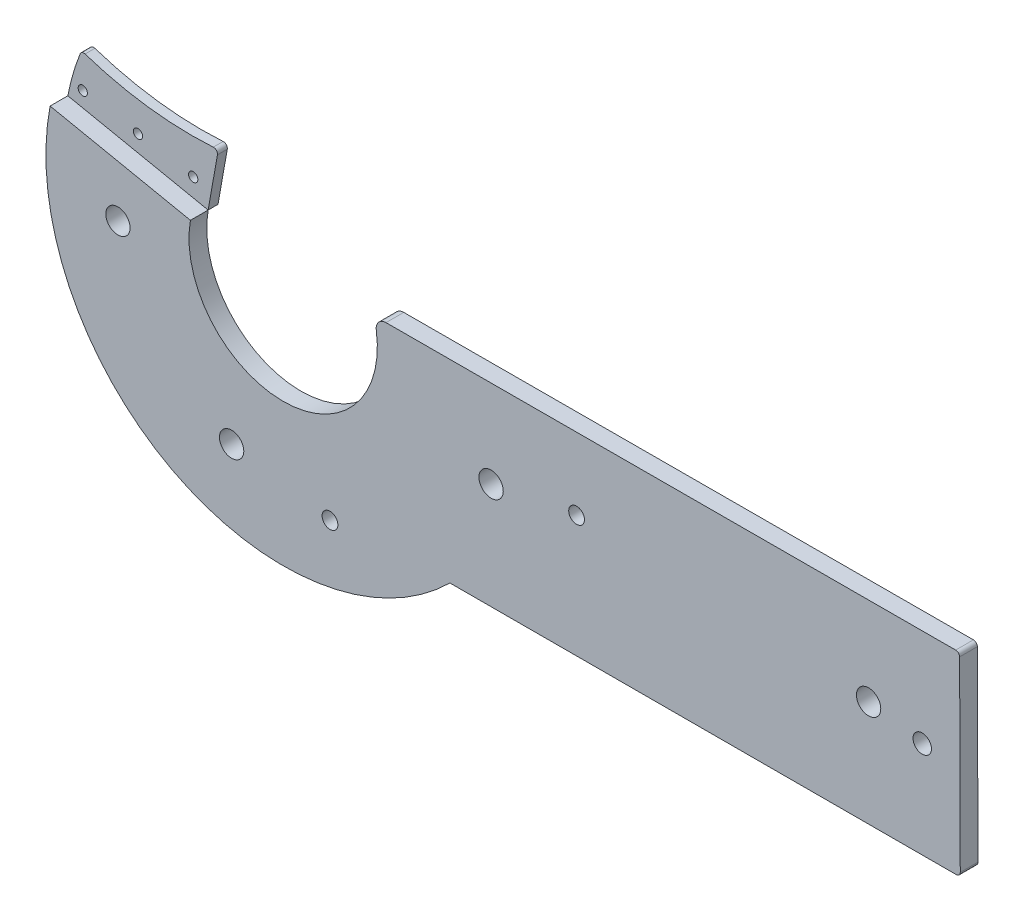
from build123d import *

# Parameters (mm, degrees)
ESBO_O1_R                = 6.175
ESBO_O1_R_2              = 4.675
ESBO_O1_R_3              = 4
RESSALTO_EXTRUS_O1_DEPTH = 9
ESBO_O3_R                = 2.35
RESSALTO_EXTRUS_O2_DEPTH = 5
FILETE1_R                = 2
FILETE2_R                = 5
FILETE3_R                = 2


with BuildPart() as part:
    # Esboço1 → Ressalto-extrusão1 (new body)
    with BuildSketch(Plane.XY):
        with BuildLine():
            Line((131.185001268, 136.941324617), (428.491868014, 137.593385628))
            Line((428.491868014, 137.593385628), (428.831279068, 39.038667427))
            Line((428.831279068, 39.038667427), (169.784133842, 38.708869148))
            ThreePointArc((169.784133842, 38.708869148), (28.491582051, 18.109560868), (-33.143087689, 146.908179569))
            Line((-33.143087689, 146.908179569), (38.078504056, 132.288651538))
            ThreePointArc((38.078504056, 132.288651538), (87.546420662, 76.2884039), (131.185001268, 136.941324617))
        make_face()
        with Locations((190.69502548, 92.615691457)):
            Circle(ESBO_O1_R, mode=Mode.SUBTRACT)
        with Locations((382.297443759, 92.723982486)):
            Circle(ESBO_O1_R, mode=Mode.SUBTRACT)
        with Locations((409.52113325, 88.004907998)):
            Circle(ESBO_O1_R_2, mode=Mode.SUBTRACT)
        with Locations((234.083144105, 100.646929333)):
            Circle(ESBO_O1_R_3, mode=Mode.SUBTRACT)
        with Locations((58.992106854, 44.327990976)):
            Circle(ESBO_O1_R, mode=Mode.SUBTRACT)
        with Locations((108.920722634, 35.826602606)):
            Circle(ESBO_O1_R_3, mode=Mode.SUBTRACT)
        with Locations((1.288049242, 113.626800727)):
            Circle(ESBO_O1_R, mode=Mode.SUBTRACT)
    extrude(amount=RESSALTO_EXTRUS_O1_DEPTH)

    # Filete2
    filete2_edges = [part.edges().sort_by_distance(p)[0] for p in [
        (131.185001268, 136.941324617, 4.5),
    ]]
    fillet(filete2_edges, radius=FILETE2_R)

    # Filete3
    filete3_edges = [part.edges().sort_by_distance(p)[0] for p in [
        (428.491868014, 137.593385628, 4.5),
        (428.831279068, 39.038667427, 4.5),
    ]]
    fillet(filete3_edges, radius=FILETE3_R)


with BuildPart() as body_2:
    # Esboço3 → Ressalto-extrusão2 (new body)
    with BuildSketch(Plane(origin=(0, 0, 0), x_dir=(-1, 0, 0), z_dir=(0, 0, -1))):
        with BuildLine():
            Line((-43.239696233, 161.428448711), (-38.078504056, 132.288651538))
            Line((-38.078504056, 132.288651538), (33.143087689, 146.908179569))
            ThreePointArc((33.143087689, 146.908179569), (30.256436099, 158.757790962), (26.1859926, 170.254639978))
            ThreePointArc((26.1859926, 170.254639978), (-8.074093344, 162.280204252), (-43.239696233, 161.428448711))
        make_face()
        with Locations((-2.467708184, 148.035842502)):
            Circle(ESBO_O3_R, mode=Mode.SUBTRACT)
        with Locations((-30.485058792, 143.0614585)):
            Circle(ESBO_O3_R, mode=Mode.SUBTRACT)
        with Locations((25.549642425, 153.010226504)):
            Circle(ESBO_O3_R, mode=Mode.SUBTRACT)
    extrude(amount=RESSALTO_EXTRUS_O2_DEPTH)

    # Filete1
    filete1_edges = [body_2.edges().sort_by_distance(p)[0] for p in [
        (43.239696233, 161.428448711, -2.5),
        (-26.1859926, 170.254639978, -2.5),
    ]]
    fillet(filete1_edges, radius=FILETE1_R)


solid = Compound([part.part, body_2.part])
